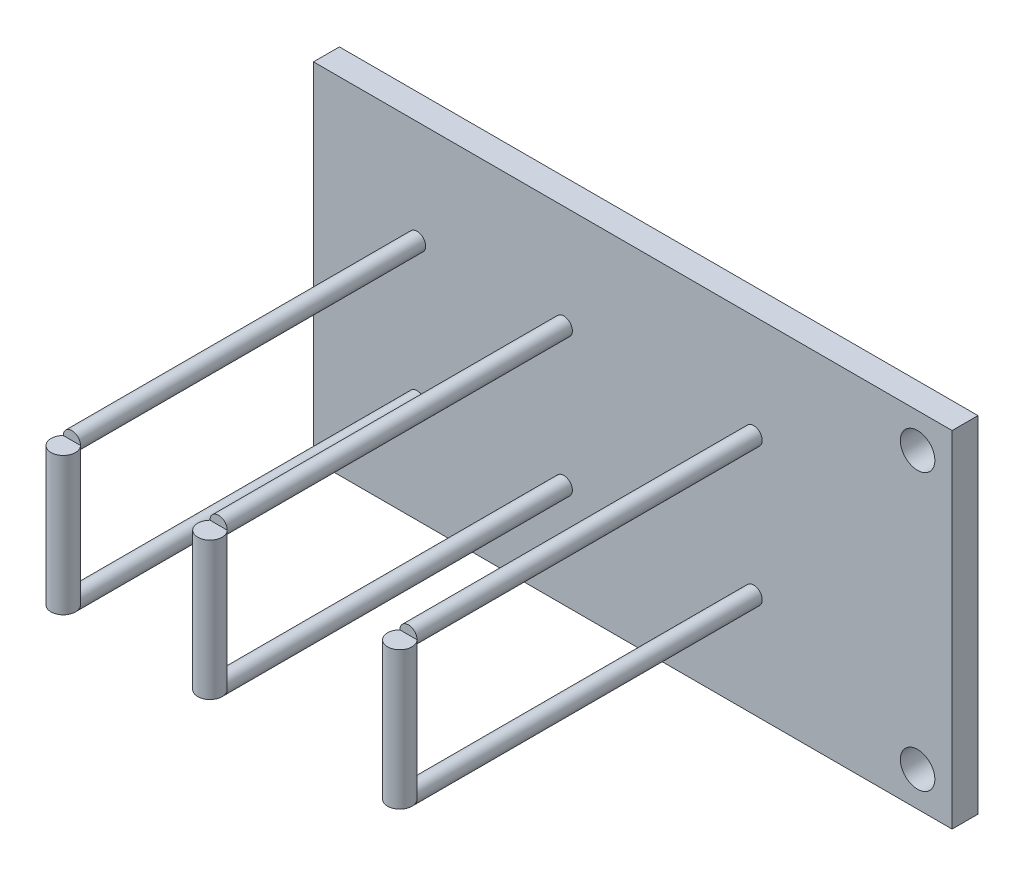
from build123d import *

# Parameters (mm, degrees)
ESBO_O1_W                = 37
ESBO_O1_H                = 20
RESSALTO_EXTRUS_O1_DEPTH = 1.5
ESBO_O2_R                = 1
CORTE_EXTRUS_O1_DEPTH    = 2.5
ESBO_O3_R                = 0.5
RESSALTO_EXTRUS_O2_DEPTH = 20
ESBO_O4_W                = 1
ESBO_O4_H                = 8
RESSALTO_EXTRUS_O3_DEPTH = 1
ESBO_O5_R                = 0.707106781
RESSALTO_EXTRUS_O4_DEPTH = 8


with BuildPart() as part:
    # Esboço1 → Ressalto-extrusão1 (new body)
    with BuildSketch(Plane.XY):
        Rectangle(ESBO_O1_W, ESBO_O1_H)
    extrude(amount=RESSALTO_EXTRUS_O1_DEPTH)

    # Esboço2 → Corte-extrusão1 (cut, through all)
    with BuildSketch(Plane.XY.offset(1.5)):
        with Locations((16.5, 8)):
            Circle(ESBO_O2_R)
        with Locations((16.5, -8)):
            Circle(ESBO_O2_R)
    extrude(amount=-CORTE_EXTRUS_O1_DEPTH, mode=Mode.SUBTRACT)

    # Esboço3 → Ressalto-extrusão2 (add)
    with BuildSketch(Plane.XY.offset(1.5)):
        with Locations((-12.5, 4)):
            Circle(ESBO_O3_R)
        with Locations((-4, 4)):
            Circle(ESBO_O3_R)
        with Locations((7, 4)):
            Circle(ESBO_O3_R)
        with Locations((7, -4)):
            Circle(ESBO_O3_R)
        with Locations((-4, -4)):
            Circle(ESBO_O3_R)
        with Locations((-12.5, -4)):
            Circle(ESBO_O3_R)
    extrude(amount=RESSALTO_EXTRUS_O2_DEPTH)

    # Esboço4 → Ressalto-extrusão3 (add)
    with BuildSketch(Plane.XY.offset(21.5)):
        with Locations((-12.5, 0)):
            Rectangle(ESBO_O4_W, ESBO_O4_H)
        with Locations((-4, 0)):
            Rectangle(ESBO_O4_W, ESBO_O4_H)
        with Locations((7, 0)):
            Rectangle(ESBO_O4_W, ESBO_O4_H)
    extrude(amount=RESSALTO_EXTRUS_O3_DEPTH)

    # Esboço5 → Ressalto-extrusão4 (add)
    with BuildSketch(Plane.XZ.offset(4)):
        with Locations((-12.5, 22)):
            Circle(ESBO_O5_R)
        with Locations((-4, 22)):
            Circle(ESBO_O5_R)
        with Locations((7, 22)):
            Circle(ESBO_O5_R)
    extrude(amount=-RESSALTO_EXTRUS_O4_DEPTH)


solid = part.part
